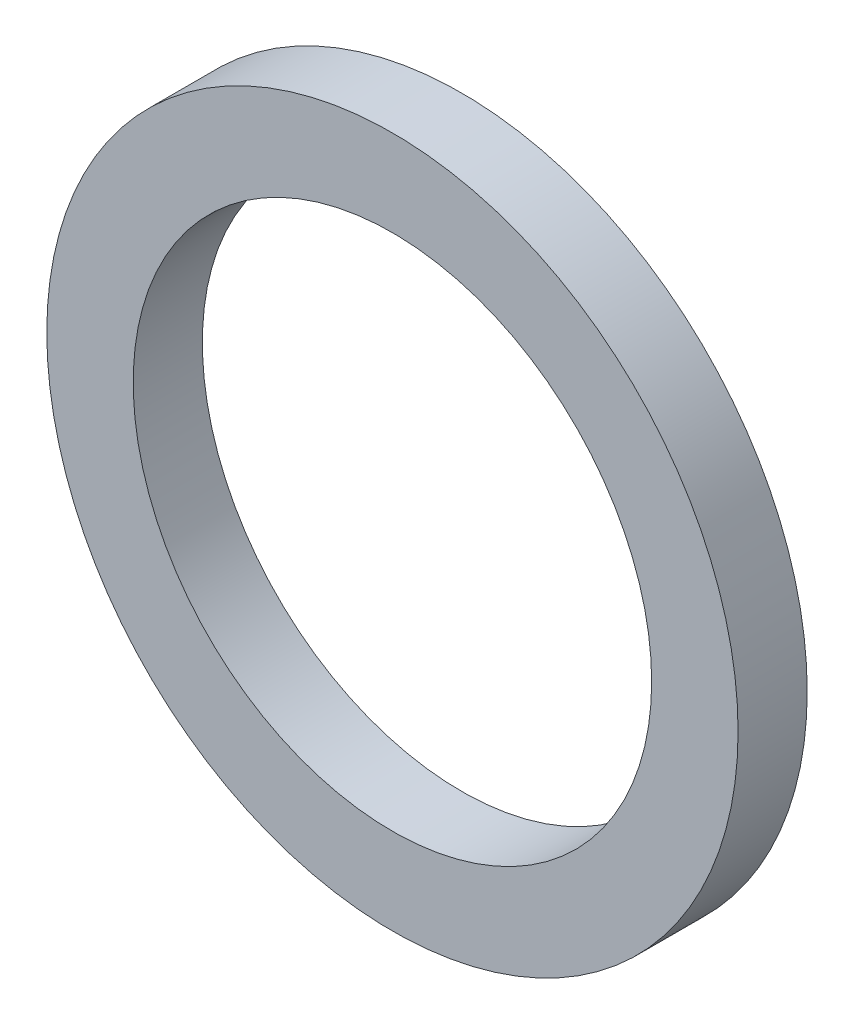
from build123d import *

# Parameters (mm, degrees)
ESQUISSE8_R      = 10
ESQUISSE8_R_2    = 7.5
EXTRUSION3_DEPTH = 2


with BuildPart() as part:
    # Esquisse8 → Extrusion3 (new body)
    with BuildSketch(Plane.XY):
        Circle(ESQUISSE8_R)
        Circle(ESQUISSE8_R_2, mode=Mode.SUBTRACT)
    extrude(amount=EXTRUSION3_DEPTH)


solid = part.part
